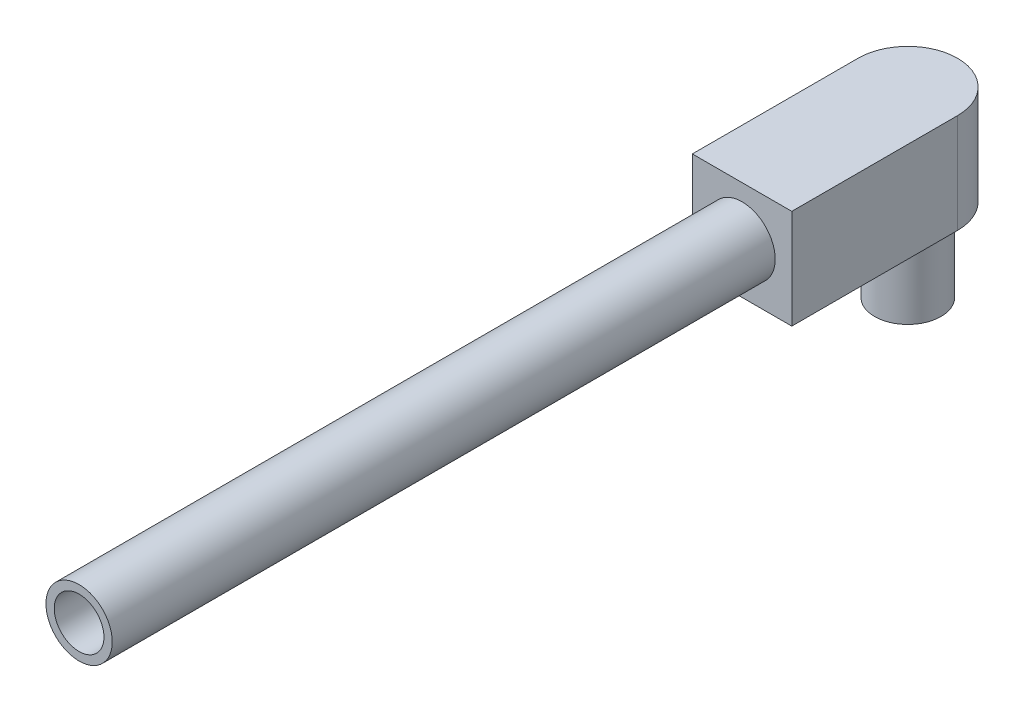
from build123d import *

# Parameters (mm, degrees)
SKETCH_1_W          = 30
SKETCH_1_H          = 30
EXTRUDE_1_DEPTH     = 5
SKETCH_2_R          = 10
SKETCH_2_R_2        = 7.5
EXTRUDE_2_DEPTH     = 200
SKETCH_3_W          = 30
SKETCH_3_H          = 30
EXTRUDE_3_DEPTH     = 60
SKETCH_4_R          = 10
EXTRUDE_4_DEPTH     = 25
CUT_EXTRUDE_1_DEPTH = 31


with BuildPart() as part:
    # 草图1 → 凸台-拉伸1 (new body)
    with BuildSketch(Plane.XY):
        Rectangle(SKETCH_1_W, SKETCH_1_H)
    extrude(amount=EXTRUDE_1_DEPTH)

    # 草图2 → 凸台-拉伸2 (add)
    with BuildSketch(Plane.XY.offset(5)):
        Circle(SKETCH_2_R)
        Circle(SKETCH_2_R_2, mode=Mode.SUBTRACT)
    extrude(amount=EXTRUDE_2_DEPTH)

    # 草图3 → 凸台-拉伸3 (add)
    with BuildSketch(Plane(origin=(0, 0, 0), x_dir=(-1, 0, 0), z_dir=(0, 0, -1))):
        Rectangle(SKETCH_3_W, SKETCH_3_H)
    extrude(amount=EXTRUDE_3_DEPTH)

    # 草图4 → 凸台-拉伸4 (add)
    with BuildSketch(Plane.XZ.offset(15)):
        with Locations((0, -45)):
            Circle(SKETCH_4_R)
    extrude(amount=EXTRUDE_4_DEPTH)

    # 草图5 → 切除-拉伸1 (cut, through all)
    with BuildSketch(Plane.XZ.offset(15)):
        with BuildLine():
            Line((15, -45), (15, -76.870462398))
            Line((15, -76.870462398), (-15, -76.870462398))
            Line((-15, -76.870462398), (-15, -45))
            ThreePointArc((-15, -45), (0, -60), (15, -45))
        make_face()
    extrude(amount=-CUT_EXTRUDE_1_DEPTH, mode=Mode.SUBTRACT)


solid = part.part
